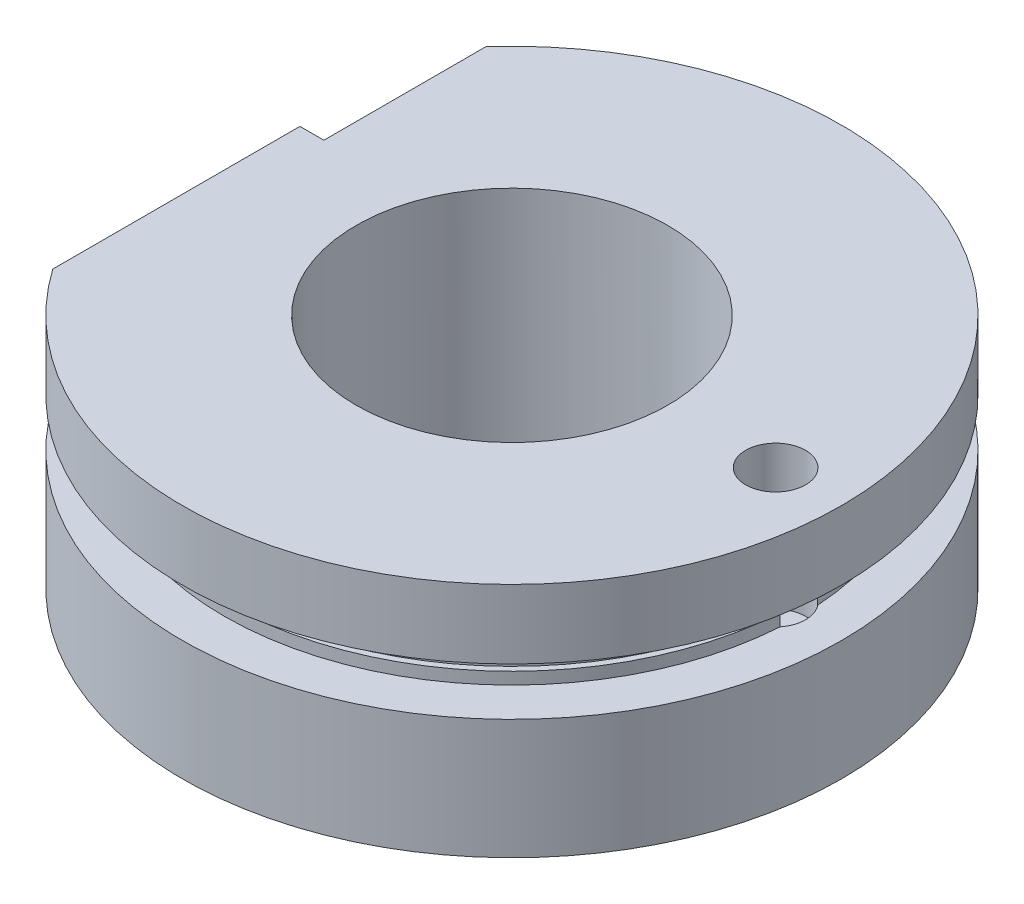
from build123d import *

# Parameters (mm, degrees)
EXTRUDE_1_DEPTH           = 19.75
SKETCH_2_R                = 13
CUT_EXTRUDE_2_DEPTH       = 20.75
CUT_EXTRUDE_4_DEPTH       = 23.69
HOLE_WIZARD_5_0_5_1_D     = 5
HOLE_WIZARD_5_0_5_1_DEPTH = 12
SKETCH_9_R                = 1
CUT_EXTRUDE_5_DEPTH       = 28.5
SWEEP_1_PITCH             = 95
SWEEP_1_HEIGHT            = 19
SWEEP_1_RADIUS            = 13
SWEEP_1_START_ANGLE       = -180
SKETCH_11_R               = 1
PATTERN_CIRCULAR_1_COUNT  = 2
PATTERN_CIRCULAR_1_ANGLE  = 17


with BuildPart() as part:
    # Эскиз1 → Бобышка-Вытянуть1 (new body)
    with BuildSketch(Plane(origin=(0, 0, 0), x_dir=(1, 0, 0), z_dir=(0, 1, 0))):
        with BuildLine():
            Line((-22.5, 15.811388301), (-22.5, -15.811388301))
            ThreePointArc((-22.5, -15.811388301), (27.5, 0), (-22.5, 15.811388301))
        make_face()
    extrude(amount=EXTRUDE_1_DEPTH)

    # Эскиз2 → Вырез-Вытянуть2 (cut, through all)
    with BuildSketch(Plane(origin=(0, 0, 0), x_dir=(1, 0, 0), z_dir=(0, 1, 0))):
        Circle(SKETCH_2_R)
    extrude(amount=CUT_EXTRUDE_2_DEPTH, mode=Mode.SUBTRACT)

    # Эскиз3 → Вырез-Повернуть1 (revolve, cut)
    with BuildSketch(Plane(origin=(0, 0, 0), x_dir=(0, 0, -1), z_dir=(1, 0, 0))):
        Polygon((-29, 14), (-24, 14), (-24, 13), (-23.5, 13), (-23.5, 11), (-24, 11), (-24, 10), (-29, 10), align=None)
    revolve(axis=Axis((0, 0, 0), (0, 1, 0)), mode=Mode.SUBTRACT)

    # Эскиз5 → Вырез-Вытянуть4 (cut, through all)
    with BuildSketch(Plane.XY.offset(-4.81)):
        Polygon((-22.5, 19.75), (-20.5, 19.75), (-22.5, 17.75), align=None)
    extrude(amount=-CUT_EXTRUDE_4_DEPTH, mode=Mode.SUBTRACT)

    # Диаметр отверстия Ø5.0 (5)1
    with Locations(Plane(origin=(0, 19.75, 0), x_dir=(1, 0, 0), z_dir=(0, 1, 0))):
        with Locations((22, 0)):
            Hole(HOLE_WIZARD_5_0_5_1_D / 2, depth=HOLE_WIZARD_5_0_5_1_DEPTH)

    # Эскиз9 → Вырез-Вытянуть5 (cut, through all)
    with BuildSketch(Plane.XY):
        with Locations((0, 12)):
            Circle(SKETCH_9_R)
    extrude(amount=CUT_EXTRUDE_5_DEPTH, mode=Mode.SUBTRACT)

    # Вырез-По траектории1: sweep along a helix
    with BuildLine() as sweep_1_path:
        add(Helix(SWEEP_1_PITCH, SWEEP_1_HEIGHT, SWEEP_1_RADIUS, center=(0, 0, 0), direction=(0, 1, 0), lefthand=True, mode=Mode.PRIVATE).rotate(Axis((0, 0, 0), (0, 1, 0)), SWEEP_1_START_ANGLE))
    # Эскиз11 → Вырез-По траектории1 (sweep, cut)
    with BuildSketch(Plane(origin=(0, 0, 0), x_dir=(1, 0, 0), z_dir=(0, 1, 0))):
        with Locations((0, 13)):
            Circle(SKETCH_11_R)
    sweep_1 = sweep(path=sweep_1_path.line, is_frenet=True, mode=Mode.SUBTRACT)

    # Круговой массив1: Вырез-По траектории1 ×2 about axis
    pattern_circular_1_axis = Axis((0, 19.75, 0), (0, -1, 0))
    for i in range(1, PATTERN_CIRCULAR_1_COUNT):
        add(sweep_1.rotate(pattern_circular_1_axis, i * PATTERN_CIRCULAR_1_ANGLE / (PATTERN_CIRCULAR_1_COUNT - 1)), mode=Mode.SUBTRACT)


solid = part.part
